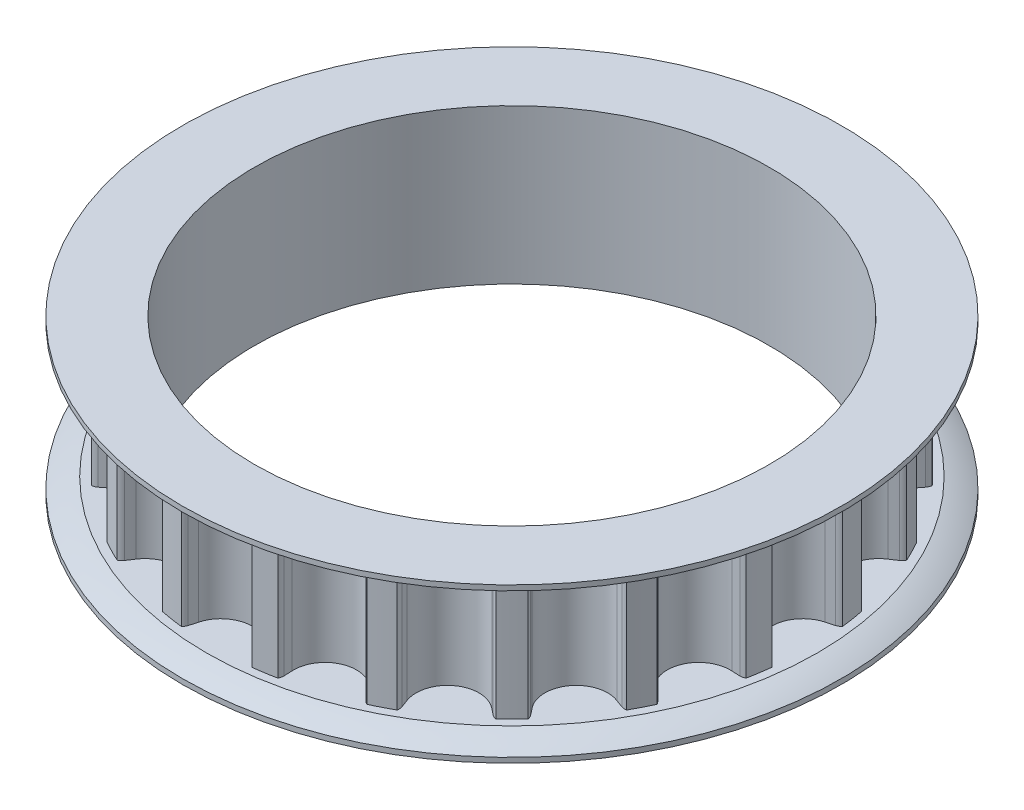
from build123d import *

# Parameters (mm, degrees)
SKETCH1_R                    = 9.168296891
TOOTHOD_DEPTH                = 1.905
TOOTHPROFILE_DEPTH           = 2.905
TOOTHPATTERN_COUNT           = 20
BORE_DEPTH                   = 3.38125
BORE_DEPTH_BACK              = 3.38125
SMALL_TOOTH_COUNT_DEPTH      = 1
SMALL_TOOTH_COUNT_DEPTH_BACK = 0.4
SKETCH12_R                   = 7.9375
CUT_EXTRUDE1_DEPTH           = 5.7625


with BuildPart() as part:
    # Sketch1 → ToothOD (new body, symmetric)
    with BuildSketch(Plane(origin=(0, 0, 0), x_dir=(1, 0, 0), z_dir=(0, 1, 0))):
        Circle(SKETCH1_R)
    extrude(amount=TOOTHOD_DEPTH, both=True)

    # Sketch2 → ToothProfile (cut, symmetric)
    with BuildSketch(Plane(origin=(0, 0, 0), x_dir=(1, 0, 0), z_dir=(0, 1, 0))):
        with BuildLine():
            ThreePointArc((-0.937033068, 8.718358887), (-0.590385173, 8.200184277), (0, 7.999896891))
            ThreePointArc((0, 7.999896891), (0.590385173, 8.200184277), (0.937033068, 8.718358887))
            ThreePointArc((0.937033068, 8.718358887), (0.971699064, 8.844470349), (1.007805813, 8.970176891))
            ThreePointArc((1.007805813, 8.970176891), (1.039709124, 9.042165511), (1.089260141, 9.10336093))
            ThreePointArc((1.089260141, 9.10336093), (0, 9.168296891), (-1.089260141, 9.10336093))
            ThreePointArc((-1.089260141, 9.10336093), (-1.039709124, 9.042165511), (-1.007805813, 8.970176891))
            ThreePointArc((-1.007805813, 8.970176891), (-0.971699064, 8.844470349), (-0.937033068, 8.718358887))
        make_face()
    toothprofile = extrude(amount=TOOTHPROFILE_DEPTH, both=True, mode=Mode.SUBTRACT)

    # ToothPattern: ToothProfile ×20 about axis
    toothpattern_axis = Axis((0, 0, 0), (0, 1, 0))
    for i in range(1, TOOTHPATTERN_COUNT):
        add(toothprofile.rotate(toothpattern_axis, i * 360 / TOOTHPATTERN_COUNT), mode=Mode.SUBTRACT)

    # Sketch4 → Flange (revolve)
    with BuildSketch(Plane.XY):
        with BuildLine():
            Line((0, -1.905), (9.422296891, -1.905))
            ThreePointArc((9.422296891, -1.905), (9.801137157, -2.040541486), (10.16, -2.2225))
            Line((10.16, -2.2225), (10.16, -2.38125))
            Line((10.16, -2.38125), (0, -2.38125))
            Line((0, -2.38125), (0, -1.905))
        make_face()
        with BuildLine():
            Line((10.16, 2.38125), (10.16, 2.2225))
            ThreePointArc((10.16, 2.2225), (9.801137157, 2.040541486), (9.422296891, 1.905))
            Line((9.422296891, 1.905), (0, 1.905))
            Line((0, 1.905), (0, 2.38125))
            Line((0, 2.38125), (10.16, 2.38125))
        make_face()
    revolve(axis=Axis((0, 8.73125, 0), (0, -1, 0)))

    # Sketch7 → Bore (cut, two sides)
    with BuildSketch(Plane.XZ) as bore_sk:
        Polygon((1.415143245, 2.4511), (-1.415143245, 2.4511), (-2.83028649, 0), (-1.415143245, -2.4511), (1.415143245, -2.4511), (2.83028649, 0), align=None)
    extrude(amount=BORE_DEPTH, mode=Mode.SUBTRACT)
    extrude(bore_sk.sketch, amount=-BORE_DEPTH_BACK, mode=Mode.SUBTRACT)

    # Sketch11 → Small Tooth Count (cut, two sides)
    with BuildSketch(Plane(origin=(0, 2.38125, 0), x_dir=(1, 0, 0), z_dir=(0, 1, 0))) as small_tooth_count_sk:
        with BuildLine():
            Line((-1.465328286, 4.499711311), (-0.582628677, 4.758672248))
            add(Edge.make_bspline(
                [(-0.582628677, 4.758672248), (-0.556998036, 4.765442759), (-0.508542965, 4.7782425), (-0.437717619, 4.788540441), (-0.373374535, 4.78938386), (-0.316019978, 4.781280577), (-0.266906863, 4.76514332), (-0.227203251, 4.741953039), (-0.197116959, 4.710977055), (-0.187424771, 4.685326194), (-0.182578677, 4.672500764)],
                knots=[0, 0, 0, 0, 7.9486e-05, 0.000150268, 0.000214117, 0.000271893, 0.000323288, 0.000368159, 0.000408916, 0.000449674, 0.000449674, 0.000449674, 0.000449674], degree=3))
            add(Edge.make_bspline(
                [(-0.182578677, 4.672500764), (-0.180090677, 4.660491722), (-0.175092696, 4.63636754), (-0.180554797, 4.597864563), (-0.195942904, 4.55928097), (-0.220762144, 4.520114823), (-0.25656991, 4.482778808), (-0.304109344, 4.449707895), (-0.362924077, 4.421120066), (-0.406937835, 4.407142571), (-0.430377505, 4.399698811)],
                knots=[0, 0, 0, 0, 3.656e-05, 7.3443e-05, 0.00011457, 0.000160526, 0.000211687, 0.000268676, 0.000333372, 0.000407078, 0.000407078, 0.000407078, 0.000407078], degree=3))
            Line((-0.430377505, 4.399698811), (-1.76670524, 4.008132014))
            add(Edge.make_bspline(
                [(-1.76670524, 4.008132014), (-1.789931796, 4.001879067), (-1.834121395, 3.989982545), (-1.899817538, 3.984531329), (-1.960471756, 3.987107454), (-2.015118928, 4.001600291), (-2.062202798, 4.024055078), (-2.100609179, 4.05362227), (-2.12979162, 4.090349271), (-2.140405175, 4.119073586), (-2.145770474, 4.133594123)],
                knots=[0, 0, 0, 0, 7.2018e-05, 0.000137018, 0.000196954, 0.000253267, 0.000305386, 0.000352455, 0.000397645, 0.000443843, 0.000443843, 0.000443843, 0.000443843], degree=3))
            add(Edge.make_bspline(
                [(-2.145770474, 4.133594123), (-2.147890015, 4.1439712), (-2.152456931, 4.166330396), (-2.152327749, 4.203606501), (-2.146387914, 4.246125681), (-2.136393842, 4.292688579), (-2.122717679, 4.340148086), (-2.105146134, 4.384403031), (-2.086309347, 4.425094191), (-2.070462898, 4.449129616), (-2.06272438, 4.46086717)],
                knots=[0, 0, 0, 0, 3.171e-05, 6.8324e-05, 0.000111077, 0.000160379, 0.0002111, 0.000259024, 0.000303155, 0.000345277, 0.000345277, 0.000345277, 0.000345277], degree=3))
            add(Edge.make_bspline(
                [(-2.06272438, 4.46086717), (-2.033058522, 4.504393614), (-1.975534267, 4.588794553), (-1.890269531, 4.710371023), (-1.808537366, 4.823039159), (-1.742494063, 4.910739164), (-1.692716178, 4.975876932), (-1.658517661, 5.019516714), (-1.626503284, 5.058852761), (-1.597865839, 5.094593343), (-1.571158551, 5.125841495), (-1.547871814, 5.153691064), (-1.526359958, 5.17687878), (-1.512685314, 5.190749422), (-1.506404849, 5.197119904)],
                knots=[0, 0, 0, 0, 0.000158023, 0.000306417, 0.000445469, 0.000575575, 0.000635764, 0.00069141, 0.000741894, 0.000787917, 0.000828792, 0.00086521, 0.000896806, 0.000923643, 0.000923643, 0.000923643, 0.000923643], degree=3))
            add(Edge.make_bspline(
                [(-1.506404849, 5.197119904), (-1.487168359, 5.217189178), (-1.449967285, 5.256000756), (-1.398932644, 5.315212533), (-1.353837962, 5.372404434), (-1.315082648, 5.428174756), (-1.282243802, 5.482228196), (-1.255440899, 5.53492841), (-1.23389482, 5.585952754), (-1.219376752, 5.63576133), (-1.209456251, 5.683243306), (-1.20658523, 5.728524534), (-1.207907128, 5.771222653), (-1.214681918, 5.798010961), (-1.217975943, 5.81103592)],
                knots=[0, 0, 0, 0, 8.3386e-05, 0.000161259, 0.000234409, 0.000301785, 0.00036488, 0.000423985, 0.00047904, 0.000530744, 0.000579429, 0.000624187, 0.000666662, 0.000706858, 0.000706858, 0.000706858, 0.000706858], degree=3))
            add(Edge.make_bspline(
                [(-1.217975943, 5.81103592), (-1.222427845, 5.824329728), (-1.231210035, 5.85055419), (-1.252340682, 5.88629353), (-1.278998213, 5.917879929), (-1.311135076, 5.945175396), (-1.347547537, 5.968425183), (-1.388489697, 5.986213394), (-1.432773871, 5.999809204), (-1.480532371, 6.00740377), (-1.530198132, 6.010714354), (-1.581161571, 6.008080833), (-1.63306801, 6.001454862), (-1.667225821, 5.992128152), (-1.684552115, 5.987397248)],
                knots=[0, 0, 0, 0, 4.1962e-05, 8.2779e-05, 0.000123653, 0.000165447, 0.000208799, 0.000252773, 0.00029896, 0.000347405, 0.000397509, 0.000448011, 0.000500293, 0.000554113, 0.000554113, 0.000554113, 0.000554113], degree=3))
            add(Edge.make_bspline(
                [(-1.684552115, 5.987397248), (-1.700766269, 5.98226197), (-1.732673648, 5.9721564), (-1.777344379, 5.950878169), (-1.818534474, 5.925793539), (-1.855672625, 5.89604787), (-1.889434726, 5.862522772), (-1.918943588, 5.824548912), (-1.945294488, 5.782787012), (-1.959186275, 5.75242952), (-1.966283755, 5.736919514)],
                knots=[0, 0, 0, 0, 5.0972e-05, 0.000100306, 0.000148013, 0.000195359, 0.000242716, 0.000290412, 0.000339349, 0.000390469, 0.000390469, 0.000390469, 0.000390469], degree=3))
            add(Edge.make_bspline(
                [(-1.966283755, 5.736919514), (-1.96739228, 5.733213932), (-1.970796238, 5.72183517), (-1.973870124, 5.697901692), (-1.979607942, 5.661825972), (-1.985411089, 5.615800217), (-1.99346843, 5.565153737), (-2.006196228, 5.515346666), (-2.024039762, 5.469404365), (-2.044364262, 5.425768624), (-2.073779696, 5.386360067), (-2.114266516, 5.352932362), (-2.165854647, 5.325808143), (-2.204626836, 5.312917134), (-2.225244693, 5.306062092)],
                knots=[0, 0, 0, 0, 1.1591e-05, 3.5594e-05, 7.2154e-05, 0.000121279, 0.000174716, 0.000225939, 0.000275113, 0.000322436, 0.000369942, 0.000421278, 0.000478613, 0.000543728, 0.000543728, 0.000543728, 0.000543728], degree=3))
            add(Edge.make_bspline(
                [(-2.225244693, 5.306062092), (-2.241518873, 5.301928343), (-2.273139523, 5.29389649), (-2.321053089, 5.291453461), (-2.366975637, 5.296210699), (-2.410217784, 5.308898609), (-2.449192594, 5.329882921), (-2.481702803, 5.359188646), (-2.507089267, 5.396408283), (-2.517011239, 5.425118306), (-2.522156802, 5.440007404)],
                knots=[0, 0, 0, 0, 5.0269e-05, 9.7672e-05, 0.000143033, 0.000188236, 0.000231994, 0.000274673, 0.000318387, 0.00036548, 0.00036548, 0.00036548, 0.00036548], degree=3))
            add(Edge.make_bspline(
                [(-2.522156802, 5.440007404), (-2.526750483, 5.457919274), (-2.536138346, 5.494524819), (-2.53947949, 5.552493978), (-2.538129783, 5.613261542), (-2.52841966, 5.676469715), (-2.511625644, 5.740905175), (-2.486793359, 5.805094591), (-2.454241814, 5.868463661), (-2.414114131, 5.931126343), (-2.364932082, 5.991928534), (-2.30768533, 6.051134459), (-2.240962116, 6.107320402), (-2.165962299, 6.161403681), (-2.081627613, 6.212115936), (-1.987796125, 6.257626252), (-1.884900531, 6.299146829), (-1.81227963, 6.321742802), (-1.774741958, 6.333422639)],
                knots=[0, 0, 0, 0, 5.5353e-05, 0.000113123, 0.000173424, 0.000237515, 0.000304441, 0.000372848, 0.000443535, 0.000517845, 0.000595663, 0.000677758, 0.000764541, 0.000856981, 0.000954916, 0.001059348, 0.001169536, 0.001287432, 0.001287432, 0.001287432, 0.001287432], degree=3))
            add(Edge.make_bspline(
                [(-1.774741958, 6.333422639), (-1.751125238, 6.340147312), (-1.704835647, 6.353327906), (-1.635821933, 6.369758658), (-1.568822402, 6.383607248), (-1.503823875, 6.395082193), (-1.440736298, 6.402462005), (-1.379833209, 6.407426177), (-1.32097802, 6.410005363), (-1.282418969, 6.408949565), (-1.263517349, 6.408432014)],
                knots=[0, 0, 0, 0, 7.3659e-05, 0.000144374, 0.000212762, 0.000278898, 0.000342308, 0.000403228, 0.000462206, 0.000518917, 0.000518917, 0.000518917, 0.000518917], degree=3))
            add(Edge.make_bspline(
                [(-1.263517349, 6.408432014), (-1.236530794, 6.406496015), (-1.183638621, 6.402701564), (-1.106715471, 6.389581607), (-1.033916625, 6.370911462), (-0.965697658, 6.346327704), (-0.901964695, 6.316870793), (-0.843413393, 6.282584139), (-0.789989356, 6.2433828), (-0.74252051, 6.199353542), (-0.700999831, 6.151770793), (-0.666235364, 6.101392775), (-0.638431526, 6.048519382), (-0.625905638, 6.011255534), (-0.61968688, 5.992755061)],
                knots=[0, 0, 0, 0, 8.1129e-05, 0.000159008, 0.00023373, 0.000306322, 0.000376236, 0.000444081, 0.000509538, 0.000574624, 0.000637921, 0.000698605, 0.000757913, 0.000816391, 0.000816391, 0.000816391, 0.000816391], degree=3))
            add(Edge.make_bspline(
                [(-0.61968688, 5.992755061), (-0.615682926, 5.977934599), (-0.607745161, 5.948553302), (-0.600867414, 5.903505135), (-0.597097993, 5.858293194), (-0.597569528, 5.812705932), (-0.602203162, 5.767046748), (-0.610176222, 5.721169404), (-0.622435641, 5.675126713), (-0.643011282, 5.614554357), (-0.673465407, 5.543123517), (-0.711917797, 5.463432331), (-0.752791275, 5.392343859), (-0.790936685, 5.338934848), (-0.824542692, 5.297365295), (-0.853066712, 5.26205062), (-0.885712962, 5.22235599), (-0.922301609, 5.178009227), (-0.96331172, 5.129684148), (-1.008186028, 5.076640631), (-1.057151426, 5.019193441), (-1.109183396, 4.958801594), (-1.160488999, 4.897621961), (-1.209429585, 4.839446121), (-1.253138062, 4.784235673), (-1.292827608, 4.733110862), (-1.328291335, 4.685755583), (-1.359125, 4.641995017), (-1.38570851, 4.601919214), (-1.400991559, 4.575827832), (-1.408178286, 4.563558576)],
                knots=[0, 0, 0, 0, 4.6023e-05, 9.1239e-05, 0.000136475, 0.000182019, 0.000227778, 0.000274023, 0.000321565, 0.000370559, 0.000465831, 0.000554291, 0.000635923, 0.000711493, 0.000750891, 0.000796285, 0.000847679, 0.000905075, 0.000968759, 0.001037819, 0.001113512, 0.00119521, 0.001276959, 0.001353048, 0.001423265, 0.001488192, 0.001547217, 0.00160073, 0.001648779, 0.001691429, 0.001691429, 0.001691429, 0.001691429], degree=3))
            add(Edge.make_bspline(
                [(-1.408178286, 4.563558576), (-1.416158019, 4.552378705), (-1.432847211, 4.528996589), (-1.45419019, 4.509753535), (-1.465328286, 4.499711311)],
                knots=[0, 0, 0, 0, 4.1079e-05, 8.5915e-05, 8.5915e-05, 8.5915e-05, 8.5915e-05], degree=3))
        make_face()
        with BuildLine():
            add(Edge.make_bspline(
                [(2.588809124, 4.870009877), (2.576650226, 4.8331291), (2.55312793, 4.761780485), (2.513407447, 4.660194112), (2.471135141, 4.567724413), (2.426188806, 4.483361277), (2.376462898, 4.405605821), (2.316979294, 4.335592622), (2.250530754, 4.269393352), (2.200104784, 4.231270827), (2.174471624, 4.211891908)],
                knots=[0, 0, 0, 0, 0.000116485, 0.000225348, 0.000327039, 0.000421326, 0.000511976, 0.000603271, 0.00069641, 0.000792707, 0.000792707, 0.000792707, 0.000792707], degree=3))
            add(Edge.make_bspline(
                [(2.174471624, 4.211891908), (2.160017345, 4.201721948), (2.130987756, 4.181296869), (2.08498524, 4.154213185), (2.036913776, 4.130020043), (1.986889423, 4.108481993), (1.934641994, 4.090250653), (1.88045468, 4.075149428), (1.824421356, 4.06263502), (1.766644804, 4.052702492), (1.707579093, 4.046540562), (1.647798245, 4.043975029), (1.587577218, 4.044288949), (1.526754029, 4.048377302), (1.465487092, 4.05597935), (1.403657053, 4.067271808), (1.341360928, 4.08187981), (1.30005127, 4.094115601), (1.279270452, 4.100270814)],
                knots=[0, 0, 0, 0, 5.3004e-05, 0.000106452, 0.000159965, 0.00021437, 0.000269723, 0.00032584, 0.000383034, 0.000441902, 0.000501612, 0.000561055, 0.000621332, 0.000682187, 0.000743824, 0.000806442, 0.000870663, 0.000935672, 0.000935672, 0.000935672, 0.000935672], degree=3))
            add(Edge.make_bspline(
                [(1.279270452, 4.100270814), (1.256548611, 4.107886639), (1.211676817, 4.122926604), (1.146885755, 4.14994342), (1.084999247, 4.179747966), (1.026267311, 4.213406794), (0.97051567, 4.250623367), (0.917134849, 4.29051094), (0.867619122, 4.334750647), (0.820728141, 4.381222779), (0.77789417, 4.43089538), (0.739191116, 4.482559226), (0.704264828, 4.536011626), (0.67463903, 4.591755319), (0.648937947, 4.649333919), (0.627540619, 4.708701122), (0.610301914, 4.770011762), (0.602666885, 4.811894516), (0.598828265, 4.832951674)],
                knots=[0, 0, 0, 0, 7.1873e-05, 0.000141937, 0.00021043, 0.000277827, 0.00034482, 0.000411436, 0.000477547, 0.000543847, 0.000609371, 0.000674111, 0.000737395, 0.000800717, 0.000863278, 0.000926409, 0.000989887, 0.001054071, 0.001054071, 0.001054071, 0.001054071], degree=3))
            add(Edge.make_bspline(
                [(0.598828265, 4.832951674), (0.595597297, 4.856429871), (0.58907419, 4.903830764), (0.586659133, 4.976405867), (0.587557452, 5.050684764), (0.59481654, 5.126816853), (0.605617448, 5.204851047), (0.622386017, 5.284337357), (0.641440299, 5.365940433), (0.658177702, 5.420168685), (0.66669389, 5.447760658)],
                knots=[0, 0, 0, 0, 7.1053e-05, 0.000143451, 0.000217579, 0.000293776, 0.000372705, 0.000453788, 0.000537389, 0.00062399, 0.00062399, 0.00062399, 0.00062399], degree=3))
            add(Edge.make_bspline(
                [(0.66669389, 5.447760658), (0.678153249, 5.48298714), (0.700498887, 5.551678437), (0.738079901, 5.650231112), (0.77742506, 5.741972277), (0.818116565, 5.82714693), (0.862123702, 5.904958829), (0.90787183, 5.976378467), (0.95695696, 6.040690765), (0.992903824, 6.079069399), (1.010486859, 6.097841908)],
                knots=[0, 0, 0, 0, 0.000111117, 0.000216677, 0.000316284, 0.000410537, 0.0004997, 0.000584285, 0.000664837, 0.000741964, 0.000741964, 0.000741964, 0.000741964], degree=3))
            add(Edge.make_bspline(
                [(1.010486859, 6.097841908), (1.025354815, 6.112008315), (1.0548482, 6.140110045), (1.101560292, 6.178783088), (1.151261965, 6.21218114), (1.202343699, 6.242339957), (1.256018131, 6.267644071), (1.311228768, 6.290010732), (1.369161472, 6.306478903), (1.428579785, 6.320099665), (1.489747914, 6.329455909), (1.552426515, 6.334423854), (1.616549864, 6.334492659), (1.681881363, 6.331697446), (1.748537356, 6.323888191), (1.816299501, 6.311665381), (1.88563941, 6.295710804), (1.931799621, 6.282040407), (1.955247796, 6.275096205)],
                knots=[0, 0, 0, 0, 6.1604e-05, 0.000122202, 0.000181645, 0.000241069, 0.000299982, 0.000359512, 0.000419555, 0.000480429, 0.000542312, 0.000605013, 0.000668861, 0.000734569, 0.000801083, 0.000870011, 0.000941058, 0.001014408, 0.001014408, 0.001014408, 0.001014408], degree=3))
            add(Edge.make_bspline(
                [(1.955247796, 6.275096205), (1.987119896, 6.264398436), (2.049460006, 6.243474175), (2.138322834, 6.204829302), (2.22053635, 6.1609275), (2.296872887, 6.11289499), (2.366134839, 6.059564914), (2.428929321, 6.002274976), (2.485269055, 5.94102532), (2.533705324, 5.875091606), (2.575818373, 5.806645717), (2.61021066, 5.735462089), (2.638487961, 5.662705338), (2.651222131, 5.612518806), (2.657567718, 5.587510267)],
                knots=[0, 0, 0, 0, 0.000100824, 0.000197207, 0.000290286, 0.00038021, 0.000467459, 0.000552154, 0.000634958, 0.000716666, 0.000797221, 0.000875697, 0.000953561, 0.001030901, 0.001030901, 0.001030901, 0.001030901], degree=3))
            add(Edge.make_bspline(
                [(2.657567718, 5.587510267), (2.662480728, 5.562576497), (2.672510114, 5.511676857), (2.679312633, 5.432122868), (2.679387906, 5.348562046), (2.674071514, 5.260849113), (2.662170574, 5.169029758), (2.644260848, 5.072862618), (2.619546646, 4.972515739), (2.59922676, 4.904751412), (2.588809124, 4.870009877)],
                knots=[0, 0, 0, 0, 7.6196e-05, 0.000155546, 0.00023904, 0.000326714, 0.000418977, 0.000516618, 0.000620035, 0.000728834, 0.000728834, 0.000728834, 0.000728834], degree=3))
        make_face()
        with BuildLine():
            add(Edge.make_bspline(
                [(1.997663812, 5.087001283), (2.003988306, 5.107666859), (2.016337433, 5.148018196), (2.033178785, 5.207440975), (2.048793885, 5.264124659), (2.060918834, 5.318481579), (2.071837607, 5.370091382), (2.080847614, 5.419040508), (2.087600924, 5.465504133), (2.093466253, 5.522469989), (2.095945705, 5.588458742), (2.090983394, 5.661693326), (2.075782706, 5.726502858), (2.055809249, 5.774384489), (2.035066811, 5.808150202), (2.016845761, 5.831136148), (1.99589069, 5.852529705), (1.972398627, 5.871968102), (1.946113747, 5.8896983), (1.91688045, 5.905028317), (1.885332736, 5.919650463), (1.862764279, 5.927063704), (1.851216937, 5.930856752)],
                knots=[0, 0, 0, 0, 6.4833e-05, 0.000126591, 0.000185292, 0.000241179, 0.000293631, 0.000343549, 0.000390464, 0.000434447, 0.000515305, 0.000588313, 0.00065394, 0.000714149, 0.000743019, 0.000772585, 0.000801948, 0.000832704, 0.00086391, 0.000896871, 0.000931642, 0.000968074, 0.000968074, 0.000968074, 0.000968074], degree=3))
            add(Edge.make_bspline(
                [(1.851216937, 5.930856752), (1.836720065, 5.934834685), (1.808498052, 5.942578789), (1.765414662, 5.947188994), (1.723755087, 5.944763795), (1.683277158, 5.936872927), (1.644349524, 5.921837985), (1.607226669, 5.899774865), (1.570628845, 5.87259974), (1.536209654, 5.837879422), (1.502365961, 5.796580529), (1.469150773, 5.747985188), (1.436676275, 5.691637164), (1.404080796, 5.628212951), (1.37207758, 5.557063113), (1.340490898, 5.478373819), (1.309209526, 5.392152976), (1.289786863, 5.33174177), (1.279716937, 5.300420814)],
                knots=[0, 0, 0, 0, 4.5048e-05, 8.7699e-05, 0.000129282, 0.000169824, 0.000210951, 0.00025376, 0.000299034, 0.000347339, 0.00039999, 0.000459064, 0.000523695, 0.000594983, 0.000672913, 0.000757648, 0.000849312, 0.000948005, 0.000948005, 0.000948005, 0.000948005], degree=3))
            add(Edge.make_bspline(
                [(1.279716937, 5.300420814), (1.272940024, 5.278567369), (1.259744647, 5.236016361), (1.241769089, 5.17337394), (1.226341504, 5.113592908), (1.212166226, 5.05669264), (1.200699782, 5.002464353), (1.191127321, 4.950975653), (1.184175944, 4.902385576), (1.176800599, 4.843287866), (1.174082704, 4.77549774), (1.17757086, 4.701041165), (1.190840707, 4.63612209), (1.212004603, 4.579952097), (1.243206423, 4.533267375), (1.282744527, 4.49495568), (1.33023579, 4.463830952), (1.366444053, 4.45078235), (1.385087249, 4.444063783)],
                knots=[0, 0, 0, 0, 6.864e-05, 0.000133649, 0.000195485, 0.000253853, 0.000309547, 0.000361742, 0.000410931, 0.000456786, 0.000540355, 0.00061416, 0.000679834, 0.00073837, 0.000793104, 0.000846778, 0.000902632, 0.000961913, 0.000961913, 0.000961913, 0.000961913], degree=3))
            add(Edge.make_bspline(
                [(1.385087249, 4.444063783), (1.396785247, 4.440542668), (1.419506893, 4.433703418), (1.45383284, 4.427768516), (1.486775798, 4.423777225), (1.518673505, 4.423889714), (1.54933265, 4.427013916), (1.579077838, 4.433143007), (1.607524325, 4.443185288), (1.644911965, 4.460137157), (1.689314703, 4.490612618), (1.738888843, 4.538097816), (1.785755846, 4.59726008), (1.821561856, 4.655122927), (1.849126799, 4.707335095), (1.870791059, 4.750856487), (1.892010133, 4.798157942), (1.913475694, 4.848854155), (1.934352883, 4.903349639), (1.955949147, 4.961088373), (1.976678469, 5.022907795), (1.990546691, 5.065264153), (1.997663812, 5.087001283)],
                knots=[0, 0, 0, 0, 3.6614e-05, 7.1118e-05, 0.000104351, 0.000136051, 0.000166572, 0.000196696, 0.000226912, 0.00025688, 0.000319663, 0.000387252, 0.000462211, 0.000545459, 0.000591001, 0.000639322, 0.000691276, 0.000746503, 0.00080446, 0.000866333, 0.000931423, 0.001000043, 0.001000043, 0.001000043, 0.001000043], degree=3))
        make_face(mode=Mode.SUBTRACT)
    extrude(amount=SMALL_TOOTH_COUNT_DEPTH, mode=Mode.SUBTRACT)
    extrude(small_tooth_count_sk.sketch, amount=-SMALL_TOOTH_COUNT_DEPTH_BACK, mode=Mode.SUBTRACT)

    # Sketch12 → Cut-Extrude1 (cut, through all)
    with BuildSketch(Plane(origin=(0, 2.38125, 0), x_dir=(1, 0, 0), z_dir=(0, 1, 0))):
        Circle(SKETCH12_R)
    extrude(amount=-CUT_EXTRUDE1_DEPTH, mode=Mode.SUBTRACT)


solid = part.part
